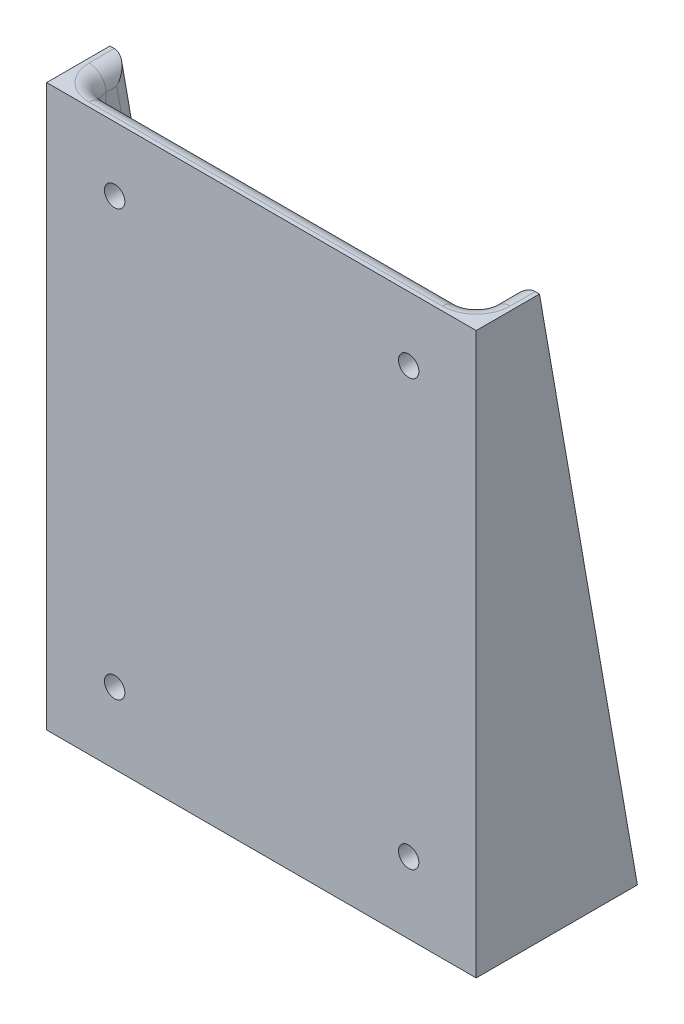
from build123d import *

# Parameters (mm, degrees)
BOSS_EXTRUDE1_DEPTH        = 32.1564
SKETCH2_W                  = 57.9628
SKETCH2_H                  = 20.955
CUT_EXTRUDE1_DEPTH         = 80.772
F_31_0_12_DIAMETER_HOLE1_D = 3.048
F_2_0_221_DIAMETER_HOLE1_D = 5.6134
FILLET1_R                  = 2.54


with BuildPart() as part:
    # Sketch1 → Boss-Extrude1 (new body, symmetric)
    with BuildSketch(Plane(origin=(0, 0, 0), x_dir=(0, 0, -1), z_dir=(1, 0, 0))):
        Polygon((0, 0), (24.13, 0), (9.4742, 83.947), (0, 83.947), align=None)
    extrude(amount=BOSS_EXTRUDE1_DEPTH, both=True)

    # Sketch2 → Cut-Extrude1 (cut)
    with BuildSketch(Plane(origin=(0, 83.947, 0), x_dir=(1, 0, 0), z_dir=(0, 1, 0))):
        with Locations((0, 13.6525)):
            Rectangle(SKETCH2_W, SKETCH2_H)
    extrude(amount=-CUT_EXTRUDE1_DEPTH, mode=Mode.SUBTRACT)

    # #31 (0.12) Diameter Hole1 (through all)
    with Locations(Plane.XY):
        with Locations((-21.971, 74.3331), (22.0472, 74.3331), (22.0472, 10.668), (-21.971, 10.668)):
            Hole(F_31_0_12_DIAMETER_HOLE1_D / 2)

    # #2 (0.221) Diameter Hole1 (through all)
    with Locations(Plane(origin=(0, 0, 0), x_dir=(-1, 0, 0), z_dir=(0, -1, 0))):
        with Locations((-16.9164, 12.065), (16.9164, 12.065)):
            Hole(F_2_0_221_DIAMETER_HOLE1_D / 2)

    # Fillet1
    fillet1_edges = [part.edges().sort_by_distance(p)[0] for p in [
        (0, 3.175, -23.575695915),
        (28.9814, 43.561, -16.524947958),
        (-28.9814, 43.561, -16.524947958),
        (-28.9814, 43.561, -3.175),
        (-28.9814, 83.947, -6.3246),
        (0, 83.947, -3.175),
        (28.9814, 83.947, -6.3246),
        (28.9814, 3.175, -13.375347958),
        (0, 3.175, -3.175),
        (-28.9814, 3.175, -13.375347958),
        (28.9814, 43.561, -3.175),
    ]]
    fillet(fillet1_edges, radius=FILLET1_R)


solid = part.part
